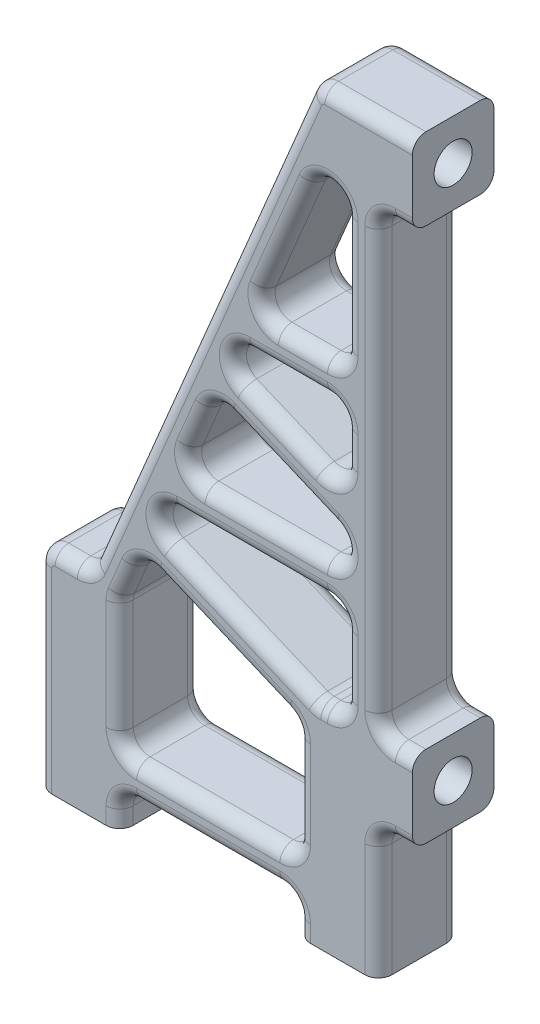
from build123d import *

# Parameters (mm, degrees)
EXTRUDE_1_DEPTH     = 6
EXTRUDE_2_DEPTH     = 6
FILLET_1_R          = 1.25
SKETCH_3_R          = 1.4
CUT_EXTRUDE_1_DEPTH = 7
SKETCH_4_R          = 1.4
CUT_EXTRUDE_2_DEPTH = 7
FILLET_7_R          = 1


with BuildPart() as part:
    # Эскиз1 → Бобышка-Вытянуть1 (new body)
    with BuildSketch(Plane.XY):
        with BuildLine():
            Line((27.55, 49), (27.55, 55))
            Line((27.55, 55), (21.113666967, 55))
            ThreePointArc((21.113666967, 55), (20.422226359, 54.79135003), (19.96161625, 54.235055816))
            Line((19.96161625, 54.235055816), (4.029534487, 16.394944184))
            ThreePointArc((4.029534487, 16.394944184), (3.568924378, 15.83864997), (2.877483769, 15.63))
            Line((2.877483769, 15.63), (1.25, 15.63))
            ThreePointArc((1.25, 15.63), (0.366116524, 15.263883476), (0, 14.38))
            Line((0, 14.38), (0, 0))
            Line((0, 0), (6, 0))
            Line((6, 0), (6, 1.25))
            ThreePointArc((6, 1.25), (6.366116524, 2.133883476), (7.25, 2.5))
            Line((7.25, 2.5), (17.8, 2.5))
            ThreePointArc((17.8, 2.5), (18.683883476, 2.133883476), (19.05, 1.25))
            Line((19.05, 1.25), (19.05, 0))
            Line((19.05, 0), (25.05, 0))
            Line((25.05, 0), (25.05, 8.38))
            ThreePointArc((25.05, 8.38), (25.416116524, 9.263883476), (26.3, 9.63))
            Line((26.3, 9.63), (27.55, 9.63))
            Line((27.55, 9.63), (27.55, 15.63))
            Line((27.55, 15.63), (26.3, 15.63))
            ThreePointArc((26.3, 15.63), (25.416116524, 15.996116524), (25.05, 16.88))
            Line((25.05, 16.88), (25.05, 47.75))
            ThreePointArc((25.05, 47.75), (25.416116524, 48.633883476), (26.3, 49))
            Line((26.3, 49), (27.55, 49))
        make_face()
        with BuildLine():
            Line((19.05, 6.25), (19.05, 14.38))
            ThreePointArc((19.05, 14.38), (19.416116524, 15.263883476), (20.3, 15.63))
            Line((20.3, 15.63), (21.3, 15.63))
            ThreePointArc((21.3, 15.63), (22.183883476, 15.996116524), (22.55, 16.88))
            Line((22.55, 16.88), (22.55, 47.75))
            ThreePointArc((22.55, 47.75), (21.547423325, 48.975268011), (20.147949283, 48.235055816))
            Line((20.147949283, 48.235055816), (6.097949283, 14.865055816))
            ThreePointArc((6.097949283, 14.865055816), (6.024731989, 14.627423325), (6, 14.38))
            Line((6, 14.38), (6, 6.25))
            ThreePointArc((6, 6.25), (6.366116524, 5.366116524), (7.25, 5))
            Line((7.25, 5), (17.8, 5))
            ThreePointArc((17.8, 5), (18.683883476, 5.366116524), (19.05, 6.25))
        make_face(mode=Mode.SUBTRACT)
    extrude(amount=EXTRUDE_1_DEPTH)

    # Эскиз2 → Бобышка-Вытянуть2 (add)
    with BuildSketch(Plane.XY):
        with BuildLine():
            Line((9.033112254, 21.836329009), (7.577944882, 18.380177038))
            Line((7.577944882, 18.380177038), (19.05, 13.55001898))
            Line((19.05, 13.55001898), (19.05, 14.38))
            ThreePointArc((19.05, 14.38), (19.416116524, 15.263883476), (20.3, 15.63))
            Line((20.3, 15.63), (20.552417555, 15.63))
            Line((20.552417555, 15.63), (9.700107232, 20.199222656))
            ThreePointArc((9.700107232, 20.199222656), (9.027553953, 20.879636665), (9.033112254, 21.836329009))
        make_face()
        with BuildLine():
            Line((15.809843094, 37.931667665), (14.435181168, 34.666723291))
            ThreePointArc((14.435181168, 34.666723291), (14.895791271, 35.223017638), (15.587231966, 35.431667665))
            Line((15.587231966, 35.431667665), (22.55, 35.431667665))
            Line((22.55, 35.431667665), (22.55, 37.931667665))
            Line((22.55, 37.931667665), (15.809843094, 37.931667665))
        make_face()
        with BuildLine():
            ThreePointArc((21.785055816, 27.503324091), (22.34135003, 27.042713982), (22.55, 26.351273374))
            Line((22.55, 26.351273374), (22.55, 29.893808584))
            Line((22.55, 29.893808584), (15.10217615, 33.029616948))
            ThreePointArc((15.10217615, 33.029616948), (14.429622873, 33.710030952), (14.435181168, 34.666723291))
            Line((14.435181168, 34.666723291), (12.9800138, 31.210571329))
            Line((12.9800138, 31.210571329), (21.785055816, 27.503324091))
        make_face()
        with BuildLine():
            Line((10.407774176, 25.101273374), (9.033112254, 21.836329009))
            ThreePointArc((9.033112254, 21.836329009), (9.493722358, 22.39262335), (10.185163048, 22.601273374))
            Line((10.185163048, 22.601273374), (22.55, 22.601273374))
            Line((22.55, 22.601273374), (22.55, 26.351273374))
            ThreePointArc((22.55, 26.351273374), (22.183883476, 25.467389897), (21.3, 25.101273374))
            Line((21.3, 25.101273374), (10.407774176, 25.101273374))
        make_face()
    extrude(amount=EXTRUDE_2_DEPTH)

    # Скругление1
    fillet_1_edges = [part.edges().sort_by_distance(p)[0] for p in [
        (20.552417555, 15.63, 3),
        (7.577944882, 18.380177038, 3),
        (19.05, 13.55001898, 3),
        (10.407774176, 25.101273374, 3),
        (22.55, 22.601273374, 3),
        (12.9800138, 31.210571329, 3),
        (22.55, 29.893808584, 3),
        (22.55, 35.431667665, 3),
        (22.55, 37.931667665, 3),
        (15.809843094, 37.931667665, 3),
    ]]
    fillet(fillet_1_edges, radius=FILLET_1_R)

    # Эскиз3 → Вырез-Вытянуть1 (cut)
    with BuildSketch(Plane(origin=(27.55, 0, 0), x_dir=(0, 0, -1), z_dir=(1, 0, 0))):
        with Locations((-3, 52)):
            Circle(SKETCH_3_R)
        with Locations((-3, 12.63)):
            Circle(SKETCH_3_R)
    extrude(amount=-CUT_EXTRUDE_1_DEPTH, mode=Mode.SUBTRACT)

    # Эскиз4 → Вырез-Вытянуть2 (cut)
    with BuildSketch(Plane.XZ):
        with Locations((3, 3)):
            Circle(SKETCH_4_R)
        with Locations((22.05, 3)):
            Circle(SKETCH_4_R)
    extrude(amount=-CUT_EXTRUDE_2_DEPTH, mode=Mode.SUBTRACT)

    # Скругление7
    fillet_7_edges = [part.edges().sort_by_distance(p)[0] for p in [
        (11.995575368, 35.315, 6),
        (8.959895037, 21.598696699, 0),
        (8.959895037, 21.598696699, 6),
        (22.525268011, 26.103850049, 6),
        (15.742581524, 22.601273374, 0),
        (15.742581524, 22.601273374, 6),
        (22.525268011, 26.103850049, 0),
        (3.568924378, 15.83864997, 6),
        (14.361963955, 34.42909099, 6),
        (17.958560167, 31.826973992, 6),
        (14.361963955, 34.42909099, 0),
        (17.958560167, 31.826973992, 0),
        (2.063741885, 15.63, 6),
        (13.507525708, 15.883604949, 0),
        (13.507525708, 15.883604949, 6),
        (15.009943263, 17.96358597, 0),
        (15.009943263, 17.96358597, 6),
        (21.052417555, 15.63, 0),
        (21.052417555, 15.63, 6),
        (6.595419175, 16.046591068, 0),
        (6.595419175, 16.046591068, 6),
        (11.816627306, 28.447424901, 0),
        (11.816627306, 28.447424901, 6),
        (16.795173672, 25.101273374, 0),
        (16.795173672, 25.101273374, 6),
        (17.958560167, 29.114419802, 0),
        (17.958560167, 29.114419802, 6),
        (0.366116524, 15.263883476, 6),
        (22.55, 32.979024709, 0),
        (22.55, 32.979024709, 6),
        (18.443615983, 35.431667665, 0),
        (18.443615983, 35.431667665, 6),
        (19.496208131, 37.931667665, 0),
        (19.496208131, 37.931667665, 6),
        (22.55, 43.465833832, 6),
        (22.55, 43.465833832, 0),
        (18.84135003, 13.411478568, 0),
        (18.84135003, 13.411478568, 6),
        (20.557411786, 15.654731989, 0),
        (20.557411786, 15.654731989, 6),
        (7.773303166, 17.900679636, 0),
        (7.773303166, 17.900679636, 6),
        (22.183883476, 22.23515685, 0),
        (22.183883476, 22.23515685, 6),
        (11.248997315, 25.659832765, 0),
        (11.248997315, 25.659832765, 6),
        (13.175372084, 30.731073927, 0),
        (26.925, 49, 0),
        (13.175372084, 30.731073927, 6),
        (21.991440608, 30.735031723, 0),
        (21.991440608, 30.735031723, 6),
        (22.183883476, 35.065551141, 0),
        (25.416116524, 48.633883476, 0),
        (22.183883476, 35.065551141, 6),
        (16.651066233, 38.490227057, 0),
        (16.651066233, 38.490227057, 6),
        (22.183883476, 38.297784189, 0),
        (25.05, 32.315, 0),
        (22.183883476, 38.297784189, 6),
        (0, 7.19, 6),
        (25.416116524, 15.996116524, 0),
        (26.925, 15.63, 0),
        (26.925, 9.63, 0),
        (25.416116524, 9.263883476, 0),
        (25.05, 4.19, 0),
        (19.05, 0.625, 0),
        (18.683883476, 2.133883476, 0),
        (12.525, 2.5, 0),
        (6.366116524, 2.133883476, 0),
        (6, 0.625, 0),
        (0, 7.19, 0),
        (0.366116524, 15.263883476, 0),
        (6, 0.625, 6),
        (2.063741885, 15.63, 0),
        (3.568924378, 15.83864997, 0),
        (11.995575368, 35.315, 0),
        (20.422226359, 54.79135003, 0),
        (24.331833484, 55, 0),
        (6.366116524, 2.133883476, 6),
        (12.525, 2.5, 6),
        (18.683883476, 2.133883476, 6),
        (24.331833484, 55, 6),
        (19.05, 0.625, 6),
        (25.05, 4.19, 6),
        (25.416116524, 9.263883476, 6),
        (26.925, 9.63, 6),
        (26.925, 15.63, 6),
        (25.416116524, 15.996116524, 6),
        (25.05, 32.315, 6),
        (21.547423325, 48.975268011, 0),
        (18.344157414, 43.950889648, 0),
        (6.024731989, 14.627423325, 0),
        (6, 10.315, 0),
        (6.366116524, 5.366116524, 0),
        (25.416116524, 48.633883476, 6),
        (12.525, 5, 0),
        (18.683883476, 5.366116524, 0),
        (19.05, 9.48501898, 0),
        (22.183883476, 15.996116524, 0),
        (22.55, 19.115636687, 0),
        (20.422226359, 54.79135003, 6),
        (26.925, 49, 6),
        (21.547423325, 48.975268011, 6),
        (18.344157414, 43.950889648, 6),
        (6.024731989, 14.627423325, 6),
        (6, 10.315, 6),
        (6.366116524, 5.366116524, 6),
        (12.525, 5, 6),
        (18.683883476, 5.366116524, 6),
        (19.05, 9.48501898, 6),
        (22.183883476, 15.996116524, 6),
        (22.55, 19.115636687, 6),
    ]]
    fillet(fillet_7_edges, radius=FILLET_7_R)


solid = part.part
